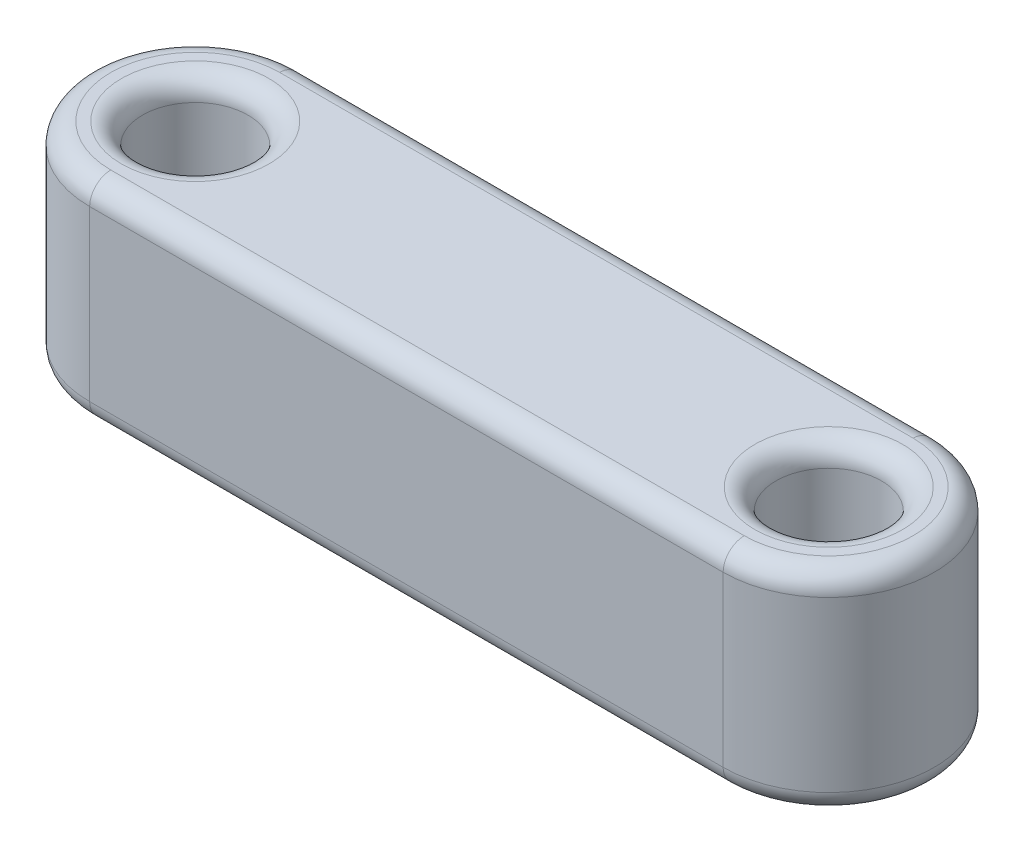
from build123d import *

# Parameters (mm, degrees)
SKETCH1_R           = 2.5
BOSS_EXTRUDE1_DEPTH = 10
FILLET1_R           = 1


with BuildPart() as part:
    # Sketch1 → Boss-Extrude1 (new body)
    with BuildSketch(Plane(origin=(0, 0, 0), x_dir=(1, 0, 0), z_dir=(0, 1, 0))):
        with BuildLine():
            Line((0, 5), (30, 5))
            ThreePointArc((30, 5), (35, 0), (30, -5))
            Line((30, -5), (0, -5))
            ThreePointArc((0, -5), (-5, 0), (0, 5))
        make_face()
        Circle(SKETCH1_R, mode=Mode.SUBTRACT)
        with Locations((30, 0)):
            Circle(SKETCH1_R, mode=Mode.SUBTRACT)
    extrude(amount=BOSS_EXTRUDE1_DEPTH)

    # Fillet1
    fillet1_edges = [part.edges().sort_by_distance(p)[0] for p in [
        (-2.5, 0, 0),
        (-2.5, 10, 0),
        (35, 10, 0),
        (27.5, 0, 0),
        (27.5, 10, 0),
        (15, 10, -5),
        (-5, 10, 0),
        (15, 0, -5),
        (35, 0, 0),
        (15, 0, 5),
        (-5, 0, 0),
        (15, 10, 5),
    ]]
    fillet(fillet1_edges, radius=FILLET1_R)


solid = part.part
